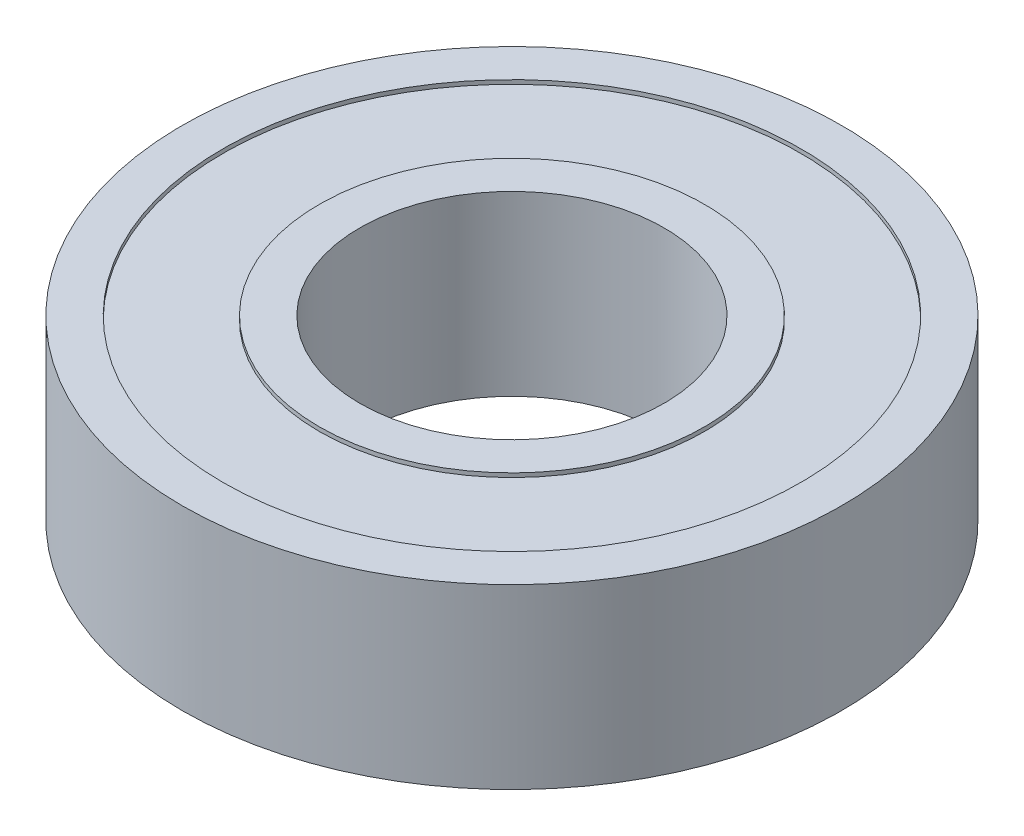
from build123d import *


with BuildPart() as part:
    # Sketch1 → Revolve1 (revolve)
    with BuildSketch(Plane.XY):
        Polygon((9.525, 0), (20.6375, 0), (20.6375, 5.55625), (18.0975, 5.55625), (18.0975, 5.30225), (12.065, 5.30225), (12.065, 5.55625), (9.525, 5.55625), align=None)
    revolve1 = revolve(axis=Axis((0, 28.620588043, 0), (0, -1, 0)))

    # Mirror1: Revolve1 across plane
    add(revolve1.mirror(Plane.ZX))


solid = part.part
